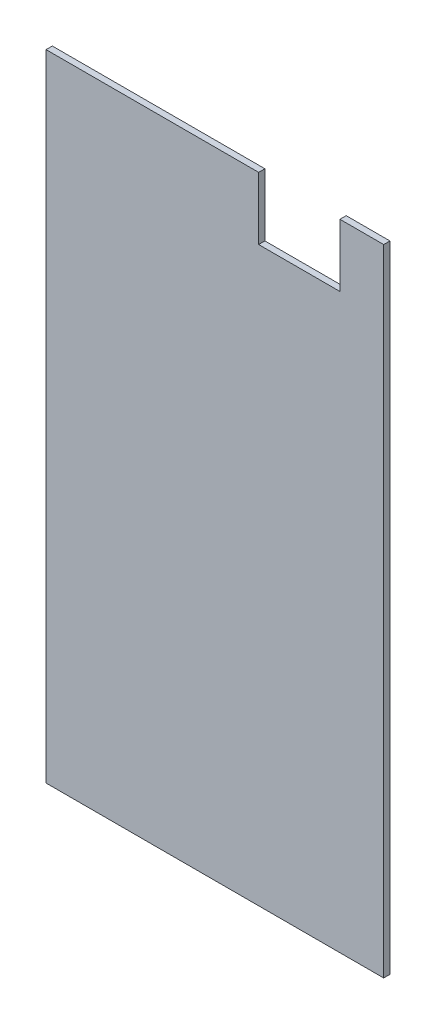
from build123d import *

# Parameters (mm, degrees)
SKETCH1_W           = 81
SKETCH1_H           = 152.4
BOSS_EXTRUDE1_DEPTH = 1.5
SKETCH3_W           = 19.5
SKETCH3_H           = 15
CUT_EXTRUDE1_DEPTH  = 10


with BuildPart() as part:
    # Sketch1 → Boss-Extrude1 (new body)
    with BuildSketch(Plane.XY):
        Rectangle(SKETCH1_W, SKETCH1_H)
    extrude(amount=BOSS_EXTRUDE1_DEPTH)

    # Sketch3 → Cut-Extrude1 (cut)
    with BuildSketch(Plane.XY.offset(1.5)):
        with Locations((20.25, 68.7)):
            Rectangle(SKETCH3_W, SKETCH3_H)
    extrude(amount=-CUT_EXTRUDE1_DEPTH, mode=Mode.SUBTRACT)


solid = part.part
